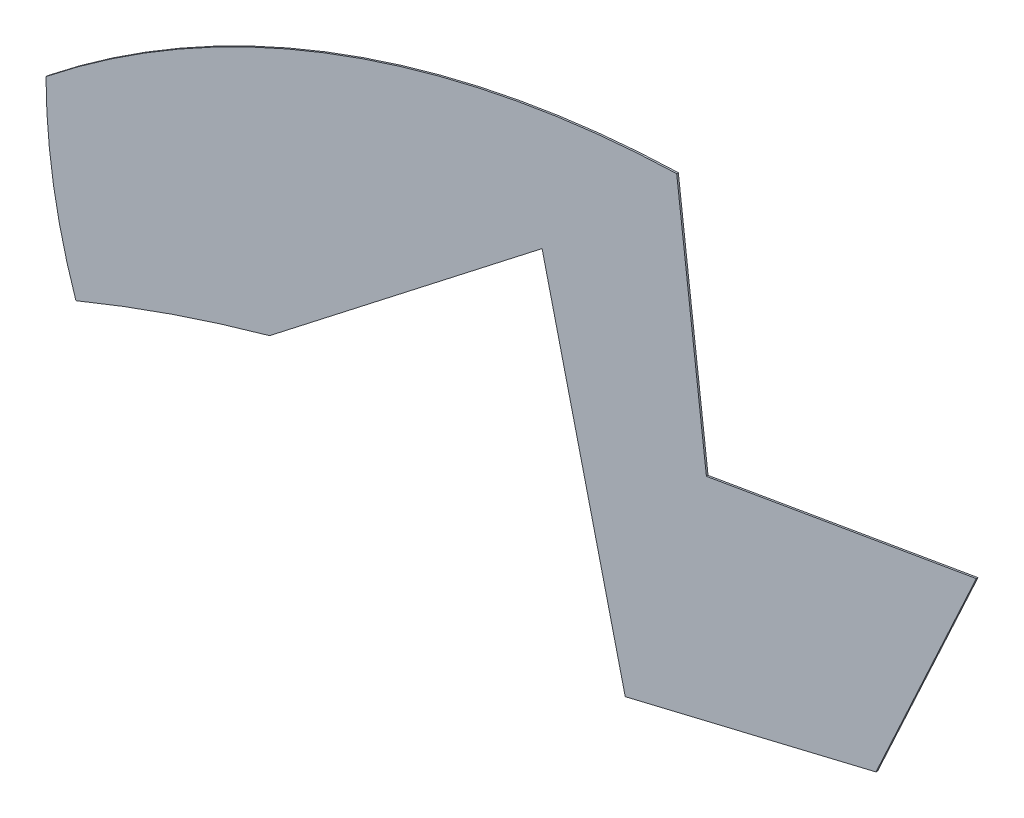
from build123d import *

# Parameters (mm, degrees)
SALIENTE_EXTRUIR1_DEPTH = 0.1


with BuildPart() as part:
    # Model → Saliente-Extruir1 (new body)
    with BuildSketch(Plane.XY):
        with BuildLine():
            Line((29.512585392, 24.480394017), (27.703067566, 39.527605983))
            ThreePointArc((27.703067566, 39.527605983), (7.377127931, 35.592311556), (-10.673926914, 25.453781916))
            ThreePointArc((-10.673926914, 25.453781916), (-10.212179423, 19.928358371), (-8.854222662, 14.552535688))
            ThreePointArc((-8.854222662, 14.552535688), (-3.021164415, 16.754836825), (2.933605753, 18.6029199))
            Line((2.933605753, 18.6029199), (19.512585392, 31.480394017))
            Line((19.512585392, 31.480394017), (24.573492595, 10.397787824))
            Line((24.573492595, 10.397787824), (39.831918887, 14.06059302))
            Line((39.831918887, 14.06059302), (45.938881991, 27.30453113))
            Line((45.938881991, 27.30453113), (29.512585392, 24.480394017))
        make_face()
    extrude(amount=SALIENTE_EXTRUIR1_DEPTH)


solid = part.part
